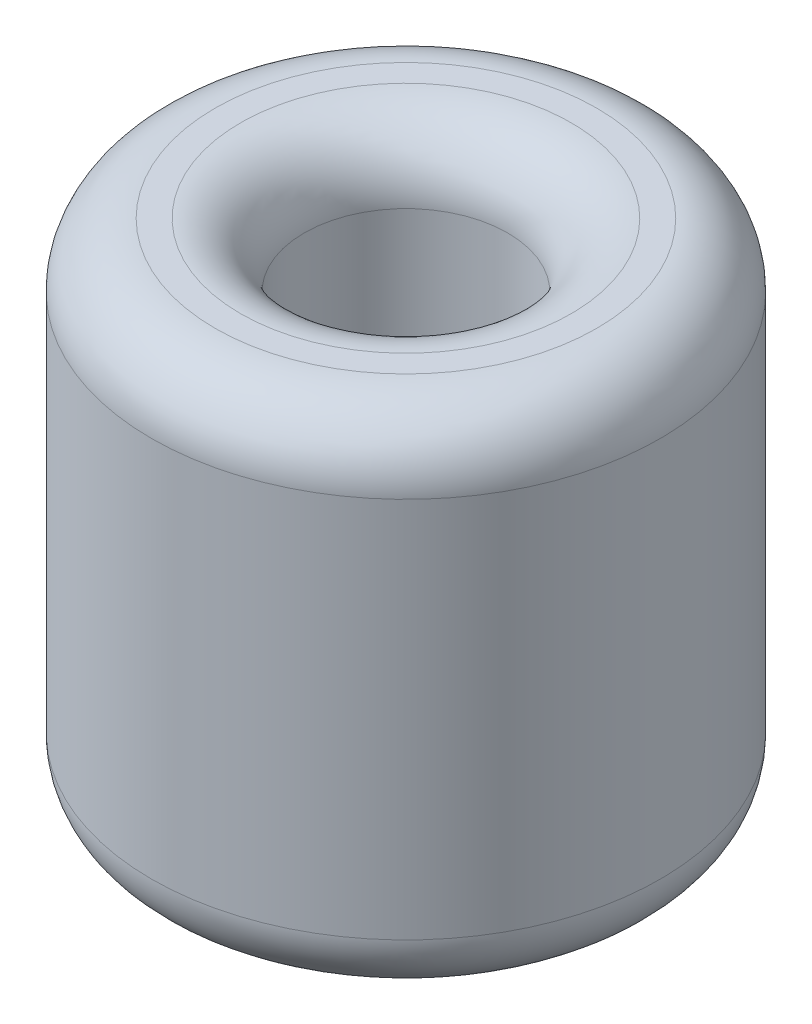
from build123d import *

# Parameters (mm, degrees)
SKETCH1_R           = 4
SKETCH1_R_2         = 1.6
BOSS_EXTRUDE1_DEPTH = 8
FILLET1_R           = 1


with BuildPart() as part:
    # Sketch1 → Boss-Extrude1 (new body)
    with BuildSketch(Plane(origin=(0, 0, 0), x_dir=(1, 0, 0), z_dir=(0, 1, 0))):
        Circle(SKETCH1_R)
        Circle(SKETCH1_R_2, mode=Mode.SUBTRACT)
    extrude(amount=BOSS_EXTRUDE1_DEPTH)

    # Fillet1
    fillet1_edges = [part.edges().sort_by_distance(p)[0] for p in [
        (-4, 0, 0),
        (-4, 8, 0),
        (-1.6, 8, 0),
    ]]
    fillet(fillet1_edges, radius=FILLET1_R)


solid = part.part
